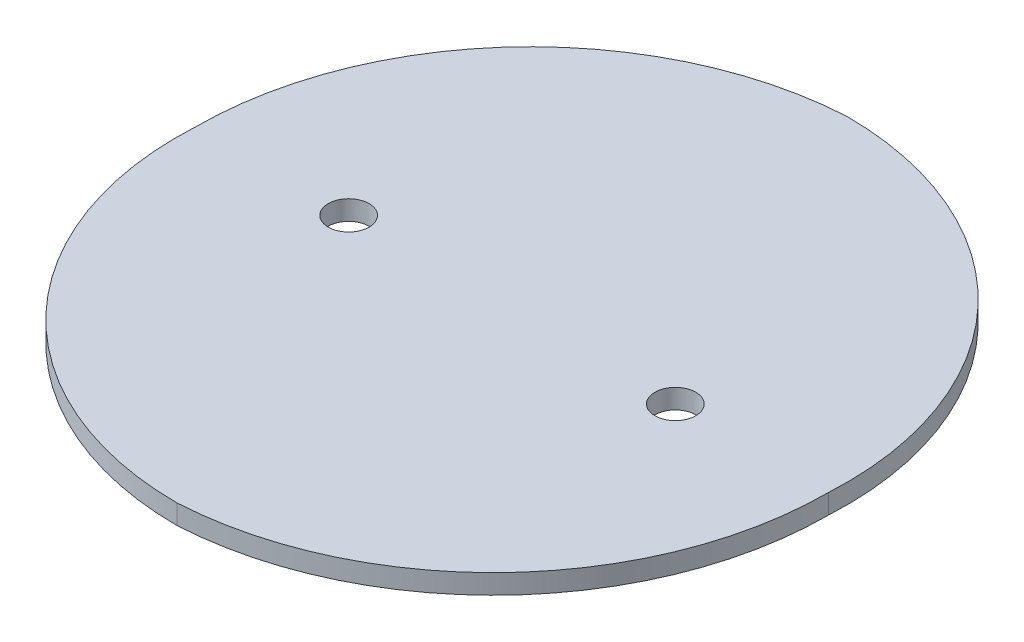
from build123d import *

# Parameters (mm, degrees)
BOSS_EXTRUDE1_DEPTH = 3
SKETCH2_R           = 6.25
CUT_EXTRUDE1_DEPTH  = 6


with BuildPart() as part:
    # Sketch1 → Boss-Extrude1 (new body, symmetric)
    with BuildSketch(Plane(origin=(0, 0, 0), x_dir=(1, 0, 0), z_dir=(0, 1, 0))):
        with BuildLine():
            ThreePointArc((-96.9, 0), (-68.840352075, 70.526342596), (0, 102.5))
            ThreePointArc((0, 102.5), (70.526342596, 72.120220464), (96.9, 0))
            ThreePointArc((96.9, 0), (68.840352075, -70.526342596), (0, -102.5))
            ThreePointArc((0, -102.5), (-70.526342596, -72.120220464), (-96.9, 0))
        make_face()
    extrude(amount=BOSS_EXTRUDE1_DEPTH, both=True)

    # Sketch2 → Cut-Extrude1 (cut)
    with BuildSketch(Plane(origin=(0, 3, 0), x_dir=(1, 0, 0), z_dir=(0, 1, 0))):
        with Locations((-50, 0)):
            Circle(SKETCH2_R)
        with Locations((50, 0)):
            Circle(SKETCH2_R)
    extrude(amount=-CUT_EXTRUDE1_DEPTH, mode=Mode.SUBTRACT)


solid = part.part
